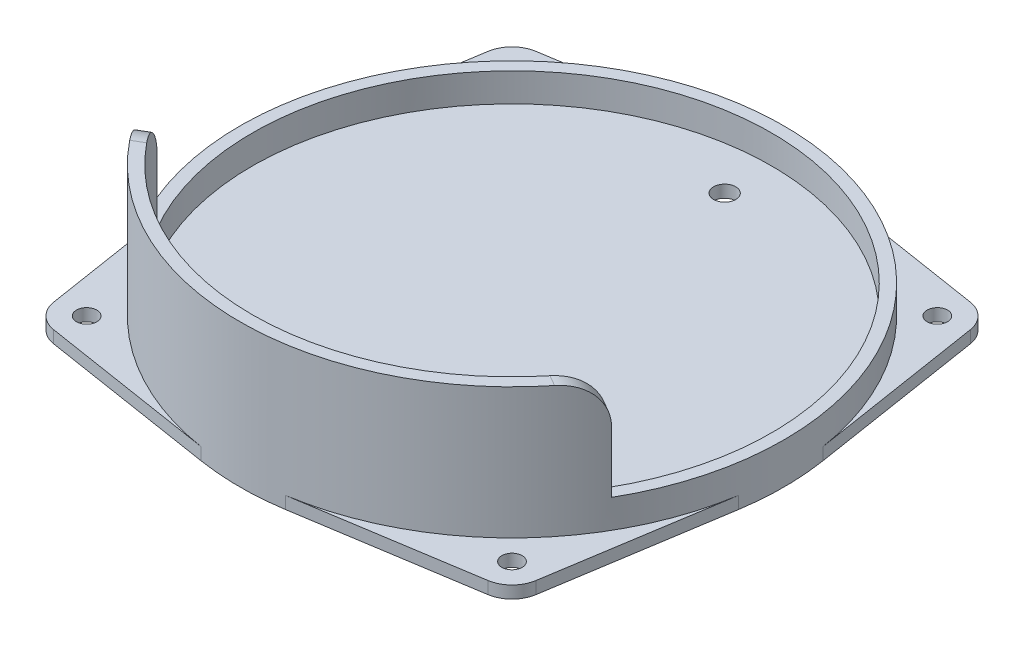
from build123d import *
from build123d.topology import SkipClean

# Parameters (mm, degrees)
SKETCH1_R               = 66.5
SKETCH1_R_2             = 63.5
EXTRUDE_THIN1_DEPTH     = 7
BOSS_EXTRUDE1_DEPTH     = 32
BOSS_EXTRUDE2_DEPTH     = 3
F_10_CLEARANCE_HOLE1_D  = 4.9784
CIRPATTERN1_COUNT       = 4
FILLET1_R               = 10
F_1_4_28_TAPPED_HOLE1_D = 5.4102


with BuildPart() as part:
    # Sketch1 → Extrude-Thin1 (new body)
    with BuildSketch(Plane(origin=(0, 0, 0), x_dir=(1, 0, 0), z_dir=(0, 1, 0))):
        Circle(SKETCH1_R)
        Circle(SKETCH1_R_2, mode=Mode.SUBTRACT)
    extrude(amount=EXTRUDE_THIN1_DEPTH)

    # Sketch2 → Boss-Extrude1 (add)
    with BuildSketch(Plane(origin=(0, 0, 0), x_dir=(1, 0, 0), z_dir=(0, 1, 0))):
        with BuildLine():
            Line((-54.99261314, -31.75), (-57.590689352, -33.25))
            ThreePointArc((-57.590689352, -33.25), (0, -66.5), (57.590689352, -33.25))
            Line((57.590689352, -33.25), (54.99261314, -31.75))
            ThreePointArc((54.99261314, -31.75), (0, -63.5), (-54.99261314, -31.75))
        make_face()
    extrude(amount=BOSS_EXTRUDE1_DEPTH)

    # Sketch3 → Boss-Extrude2 (add)
    with BuildSketch(Plane(origin=(0, 0, 0), x_dir=(1, 0, 0), z_dir=(0, 1, 0))):
        with BuildLine():
            Line((0, 0), (0, 66.5))
            ThreePointArc((0, 66.5), (5.191860277, 66.297017933), (10.352025681, 65.689310883))
            Line((10.352025681, 65.689310883), (53.09577441, 58.953292822))
            ThreePointArc((53.09577441, 58.953292822), (56.977399051, 56.977399051), (58.953292822, 53.09577441))
            Line((58.953292822, 53.09577441), (65.689310883, 10.352025681))
            ThreePointArc((65.689310883, 10.352025681), (66.297017933, 5.191860277), (66.5, 0))
            Line((66.5, 0), (0, 0))
        make_face()
    boss_extrude2 = extrude(amount=-BOSS_EXTRUDE2_DEPTH)

    # #10 Clearance Hole1 (through all)
    with Locations(Plane(origin=(0, 0, 0), x_dir=(1, 0, 0), z_dir=(0, 1, 0))):
        with Locations((52, 52)):
            f_10_clearance_hole1 = Hole(F_10_CLEARANCE_HOLE1_D / 2)

    # CirPattern1: Boss-Extrude2, #10 Clearance Hole1 ×4 about axis
    with SkipClean():  # keep this step's faces unmerged: merging them makes the solid invalid here
        cirpattern1_axis = Axis((0, 0, 0), (0, 1, 0))
        add([boss_extrude2.rotate(cirpattern1_axis, i * 360 / CIRPATTERN1_COUNT) for i in range(1, CIRPATTERN1_COUNT)])
        add([f_10_clearance_hole1.rotate(cirpattern1_axis, i * 360 / CIRPATTERN1_COUNT) for i in range(1, CIRPATTERN1_COUNT)], mode=Mode.SUBTRACT)

    # Fillet1
    fillet1_edges = [part.edges().sort_by_distance(p)[0] for p in [
        (-56.291651246, 32, 32.5),
        (56.291651246, 32, 32.5),
    ]]
    fillet(fillet1_edges, radius=FILLET1_R)

    # 1/4-28 Tapped Hole1 (through all)
    with Locations(Plane(origin=(0, 0, 0), x_dir=(1, 0, 0), z_dir=(0, 1, 0))):
        with Locations((0, 52)):
            Hole(F_1_4_28_TAPPED_HOLE1_D / 2)


solid = part.part
